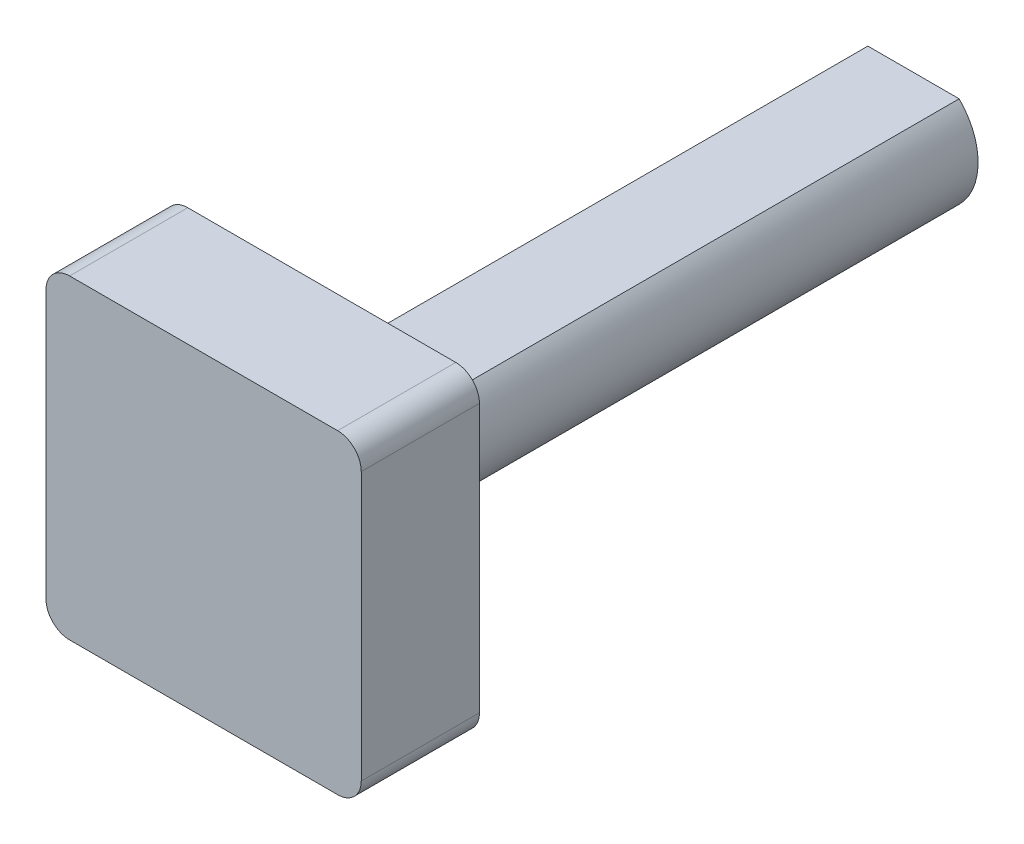
from build123d import *

# Parameters (mm, degrees)
BOSS_EXTRUDE1_DEPTH = 114.3
BOSS_EXTRUDE2_DEPTH = 19.05


with BuildPart() as part:
    # Sketch2 → Boss-Extrude1 (new body)
    with BuildSketch(Plane.XY):
        with BuildLine():
            Line((-7.31960848, -7.119729616), (7.399296286, -7.119729616))
            ThreePointArc((7.399296286, -7.119729616), (10.453843903, 0.248435463), (7.399296286, 7.616600541))
            Line((7.399296286, 7.616600541), (-7.31960848, 7.616600541))
            ThreePointArc((-7.31960848, 7.616600541), (-10.374156097, 0.248435463), (-7.31960848, -7.119729616))
        make_face()
    extrude(amount=-BOSS_EXTRUDE1_DEPTH)

    # Sketch1 → Boss-Extrude2 (add)
    with BuildSketch(Plane.XY):
        with BuildLine():
            Line((-21.701618149, -25.338055696), (21.501073099, -25.338055696))
            ThreePointArc((21.501073099, -25.338055696), (24.195149936, -24.222132532), (25.311073099, -21.528055696))
            Line((25.311073099, -21.528055696), (25.311073099, 21.674635553))
            ThreePointArc((25.311073099, 21.674635553), (24.195149936, 24.368712389), (21.501073099, 25.484635553))
            Line((21.501073099, 25.484635553), (-21.701618149, 25.484635553))
            ThreePointArc((-21.701618149, 25.484635553), (-24.395694985, 24.368712389), (-25.511618149, 21.674635553))
            Line((-25.511618149, 21.674635553), (-25.511618149, -21.528055696))
            ThreePointArc((-25.511618149, -21.528055696), (-24.395694985, -24.222132532), (-21.701618149, -25.338055696))
        make_face()
    extrude(amount=-BOSS_EXTRUDE2_DEPTH)


solid = part.part
